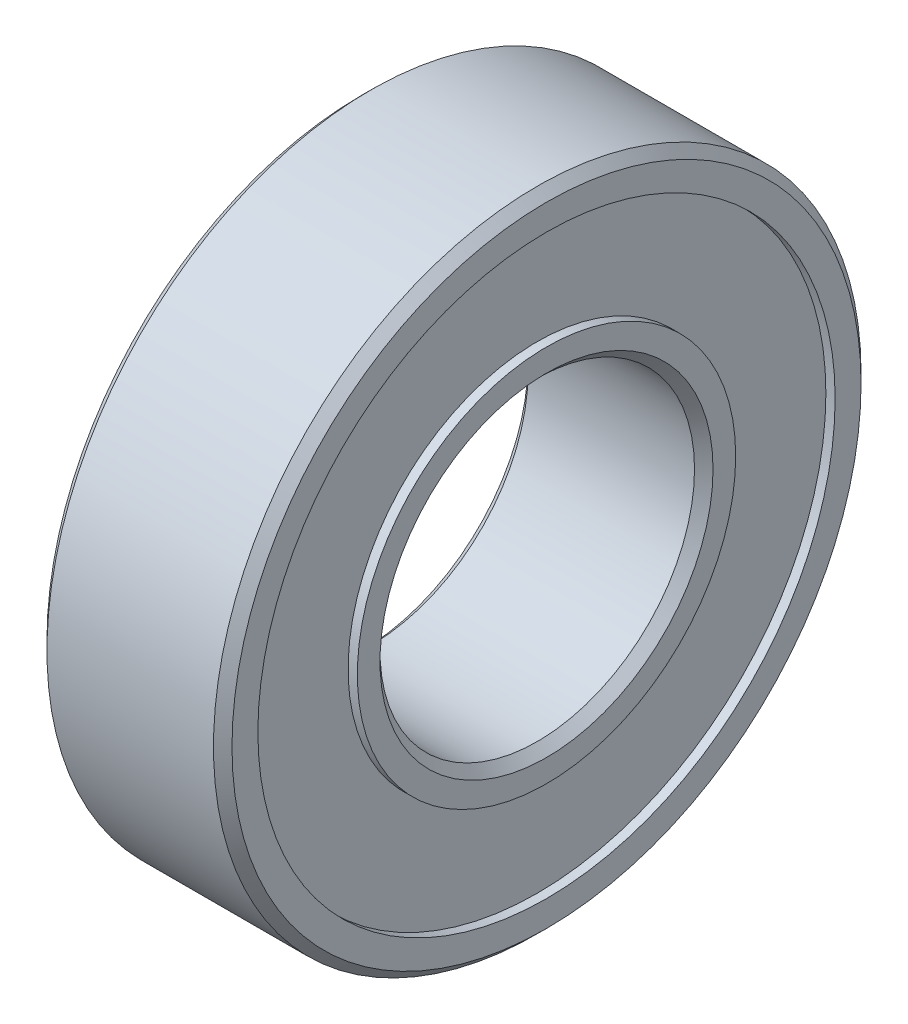
from build123d import *

# Parameters (mm, degrees)
SKETCH1_R           = 17.5
SKETCH1_R_2         = 8.5
BOSS_EXTRUDE1_DEPTH = 10
CHAMFER1_SIZE       = 0.5
SKETCH2_R           = 15.6
SKETCH2_R_2         = 10.225
CUT_EXTRUDE1_DEPTH  = 0.5
SKETCH3_R           = 15.6
SKETCH3_R_2         = 10.225
CUT_EXTRUDE2_DEPTH  = 0.5


with BuildPart() as part:
    # Sketch1 → Boss-Extrude1 (new body)
    with BuildSketch(Plane(origin=(0, 0, 0), x_dir=(0, 0, -1), z_dir=(1, 0, 0))):
        Circle(SKETCH1_R)
        Circle(SKETCH1_R_2, mode=Mode.SUBTRACT)
    extrude(amount=BOSS_EXTRUDE1_DEPTH)

    # Chamfer1
    chamfer1_edges = [part.edges().sort_by_distance(p)[0] for p in [
        (0, 0, 17.5),
        (10, 0, 17.5),
        (0, 0, 8.5),
        (10, 0, 8.5),
    ]]
    chamfer(chamfer1_edges, length=CHAMFER1_SIZE)

    # Sketch2 → Cut-Extrude1 (cut)
    with BuildSketch(Plane(origin=(10, 0, 0), x_dir=(0, 0, -1), z_dir=(1, 0, 0))):
        Circle(SKETCH2_R)
        Circle(SKETCH2_R_2, mode=Mode.SUBTRACT)
    extrude(amount=-CUT_EXTRUDE1_DEPTH, mode=Mode.SUBTRACT)

    # Sketch3 → Cut-Extrude2 (cut)
    with BuildSketch(Plane.ZY):
        Circle(SKETCH3_R)
        Circle(SKETCH3_R_2, mode=Mode.SUBTRACT)
    extrude(amount=-CUT_EXTRUDE2_DEPTH, mode=Mode.SUBTRACT)


solid = part.part
